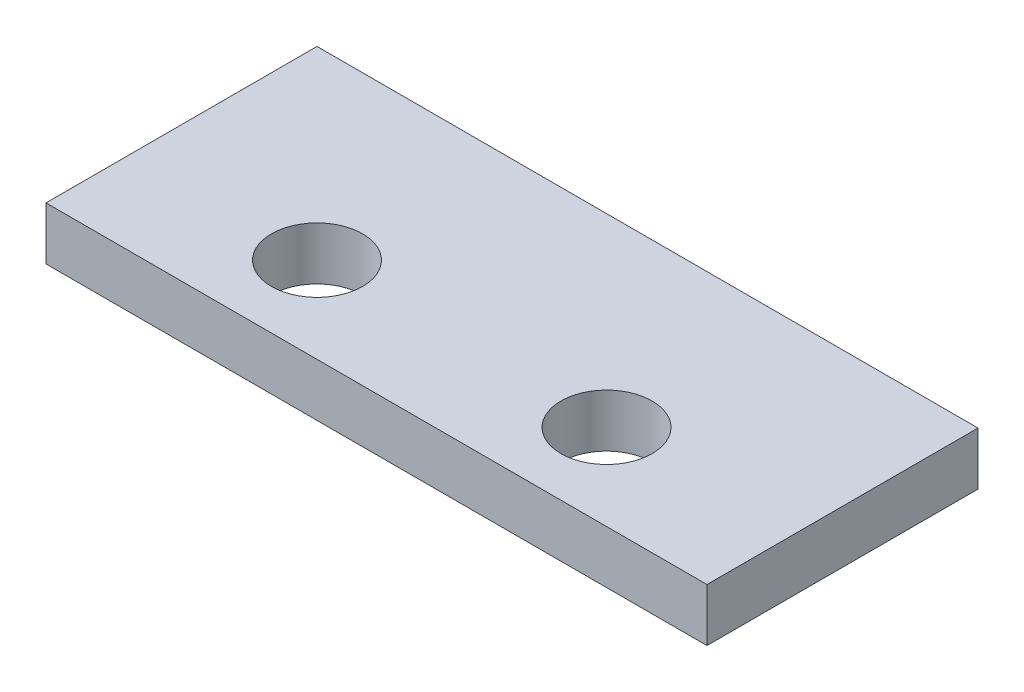
from build123d import *

# Parameters (mm, degrees)
SKETCH1_W           = 25.4
SKETCH1_H           = 10.414
SKETCH1_R           = 1.7526
BOSS_EXTRUDE1_DEPTH = 2.032


with BuildPart() as part:
    # Sketch1 → Boss-Extrude1 (new body)
    with BuildSketch(Plane(origin=(0, 0, 0), x_dir=(1, 0, 0), z_dir=(0, 1, 0))):
        with Locations((1.049586777, -2.678020661)):
            Rectangle(SKETCH1_W, SKETCH1_H)
        with Locations((-4.538413223, -4.583020661)):
            Circle(SKETCH1_R, mode=Mode.SUBTRACT)
        with Locations((6.586786777, -4.583020661)):
            Circle(SKETCH1_R, mode=Mode.SUBTRACT)
    extrude(amount=BOSS_EXTRUDE1_DEPTH)


solid = part.part
